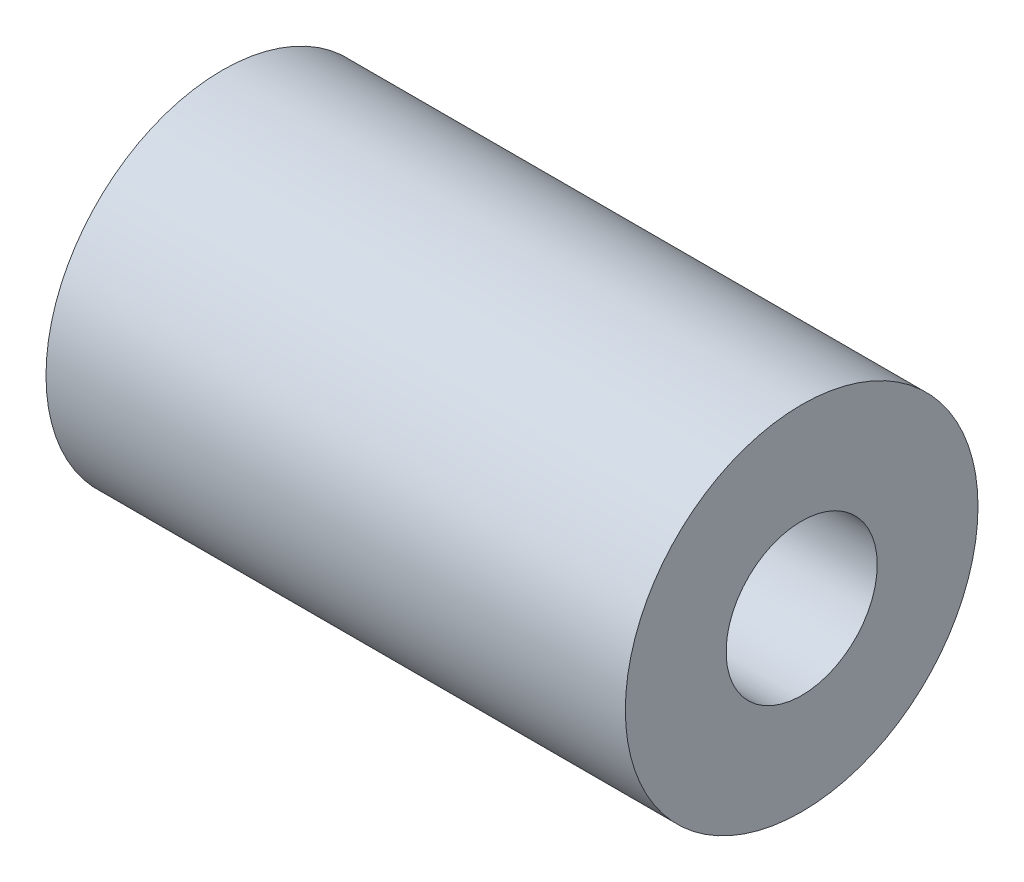
from build123d import *

# Parameters (mm, degrees)
SKETCH_1_R      = 3.5
SKETCH_1_R_2    = 1.5
EXTRUDE_1_DEPTH = 11.5


with BuildPart() as part:
    # 草图1 → 凸台-拉伸1 (new body)
    with BuildSketch(Plane(origin=(0, 0, 0), x_dir=(0, 0, -1), z_dir=(1, 0, 0))):
        Circle(SKETCH_1_R)
        Circle(SKETCH_1_R_2, mode=Mode.SUBTRACT)
    extrude(amount=EXTRUDE_1_DEPTH)


solid = part.part
